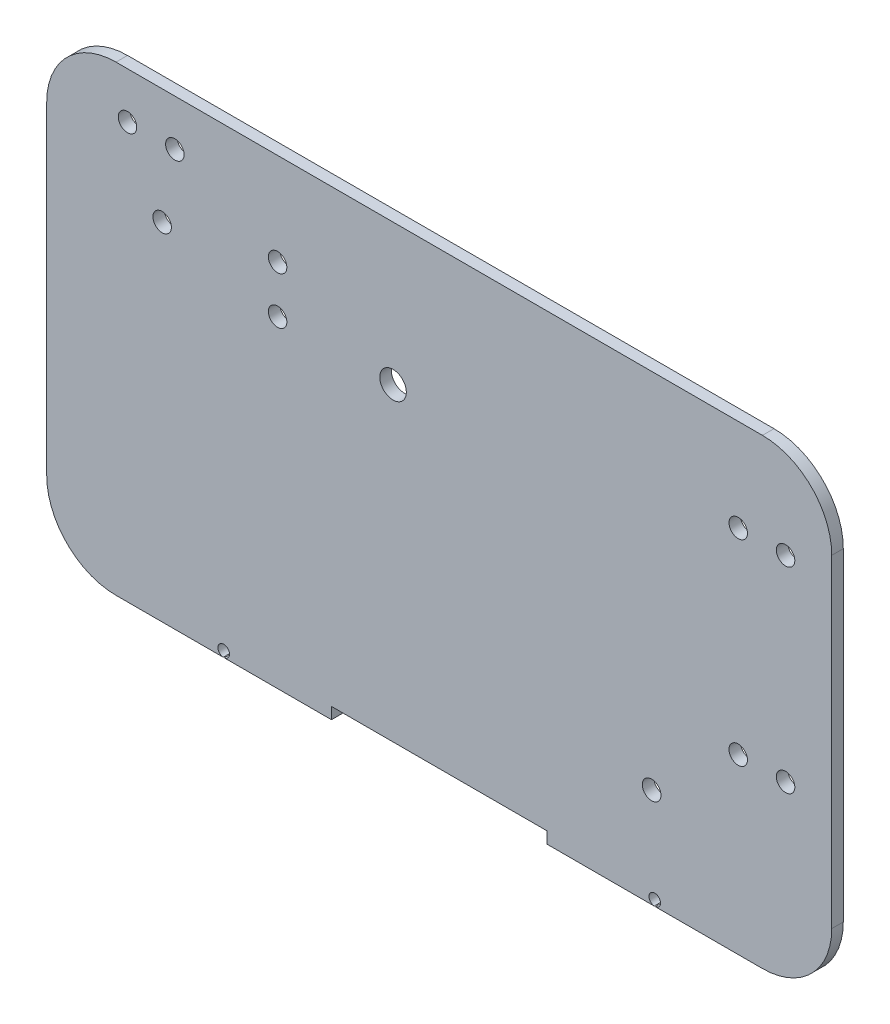
from build123d import *

# Parameters (mm, degrees)
CROQUIS1_R              = 4
CROQUIS1_R_2            = 5.75
CROQUIS1_R_3            = 4.05
SALIENTE_EXTRUIR1_DEPTH = 5
CROQUIS3_W              = 93.333333333
CROQUIS3_H              = 5
CORTAR_EXTRUIR1_DEPTH   = 10
CROQUIS6_R              = 2.5
CORTAR_EXTRUIR2_DEPTH   = 10


with BuildPart() as part:
    # Croquis1 → Saliente-Extruir1 (new body)
    with BuildSketch(Plane.XY):
        with BuildLine():
            Line((-125.472429705, -88.332065653), (154.527570295, -88.332065653))
            ThreePointArc((154.527570295, -88.332065653), (175.740773731, -79.545269088), (184.527570295, -58.332065653))
            Line((184.527570295, -58.332065653), (184.527570295, 81.667934347))
            ThreePointArc((184.527570295, 81.667934347), (175.740773731, 102.881137783), (154.527570295, 111.667934347))
            Line((154.527570295, 111.667934347), (-125.472429705, 111.667934347))
            ThreePointArc((-125.472429705, 111.667934347), (-146.68563314, 102.881137783), (-155.472429705, 81.667934347))
            Line((-155.472429705, 81.667934347), (-155.472429705, -58.332065653))
            ThreePointArc((-155.472429705, -58.332065653), (-146.68563314, -79.545269088), (-125.472429705, -88.332065653))
        make_face()
        with Locations((-105.472429705, 61.667934347)):
            Circle(CROQUIS1_R, mode=Mode.SUBTRACT)
        with Locations((-55.472429705, 71.667934347)):
            Circle(CROQUIS1_R, mode=Mode.SUBTRACT)
        with Locations((-55.472429705, 51.167934347)):
            Circle(CROQUIS1_R, mode=Mode.SUBTRACT)
        with Locations((144.027570295, -13.332065653)):
            Circle(CROQUIS1_R, mode=Mode.SUBTRACT)
        with Locations((164.527570295, -13.332065653)):
            Circle(CROQUIS1_R, mode=Mode.SUBTRACT)
        with Locations((144.027570295, 71.667934347)):
            Circle(CROQUIS1_R, mode=Mode.SUBTRACT)
        with Locations((164.527570295, 71.667934347)):
            Circle(CROQUIS1_R, mode=Mode.SUBTRACT)
        with Locations((-99.972429705, 91.667934347)):
            Circle(CROQUIS1_R, mode=Mode.SUBTRACT)
        with Locations((-120.472429705, 91.667934347)):
            Circle(CROQUIS1_R, mode=Mode.SUBTRACT)
        with Locations((-5.472429705, 50.667934347)):
            Circle(CROQUIS1_R_2, mode=Mode.SUBTRACT)
        with Locations((106.527570295, -45.332065653)):
            Circle(CROQUIS1_R_3, mode=Mode.SUBTRACT)
    extrude(amount=SALIENTE_EXTRUIR1_DEPTH)

    # Croquis3 → Cortar-Extruir1 (cut)
    with BuildSketch(Plane.XY.offset(5)):
        with Locations((14.527570296, -85.832065653)):
            Rectangle(CROQUIS3_W, CROQUIS3_H)
    extrude(amount=-CORTAR_EXTRUIR1_DEPTH, mode=Mode.SUBTRACT)

    # Croquis6 → Cortar-Extruir2 (cut)
    with BuildSketch(Plane.XY.offset(5)):
        with Locations((-78.805763038, -85.842065653)):
            Circle(CROQUIS6_R)
        with Locations((107.860903629, -85.842065653)):
            Circle(CROQUIS6_R)
    extrude(amount=-CORTAR_EXTRUIR2_DEPTH, mode=Mode.SUBTRACT)


solid = part.part
